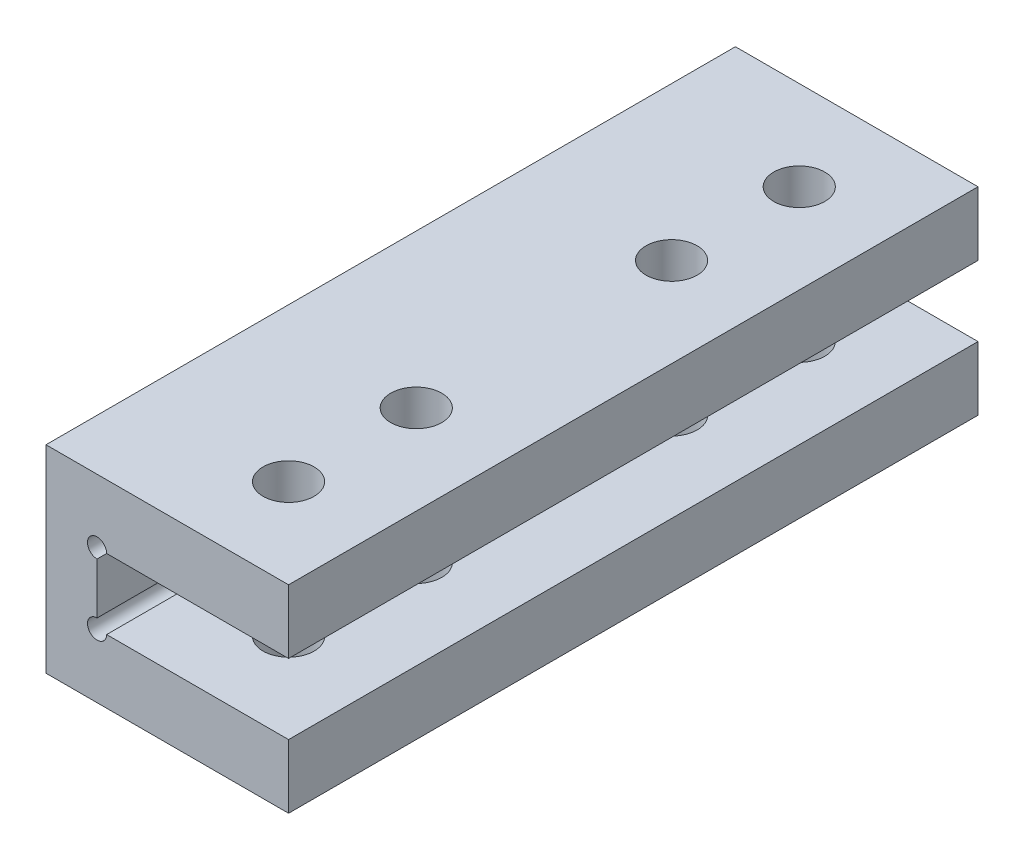
from build123d import *

# Parameters (mm, degrees)
SKETCH1_W           = 15
SKETCH1_H           = 27
SKETCH1_R           = 2
BOSS_EXTRUDE1_DEPTH = 5
SKETCH2_W           = 4
SKETCH2_H           = 10.5
BOSS_EXTRUDE2_DEPTH = 27
SKETCH4_R           = 0.75
CUT_EXTRUDE1_DEPTH  = 54


with BuildPart() as part:
    # Sketch1 → Boss-Extrude1 (new body)
    with BuildSketch(Plane(origin=(0, 0, 0), x_dir=(1, 0, 0), z_dir=(0, 1, 0))):
        with Locations((7.5, 13.5)):
            Rectangle(SKETCH1_W, SKETCH1_H)
        with Locations((8, 10)):
            Circle(SKETCH1_R, mode=Mode.SUBTRACT)
        with Locations((8, 20)):
            Circle(SKETCH1_R, mode=Mode.SUBTRACT)
    extrude(amount=BOSS_EXTRUDE1_DEPTH)

    # Sketch2 → Boss-Extrude2 (add)
    with BuildSketch(Plane.XY):
        with Locations((-2, -0.25)):
            Rectangle(SKETCH2_W, SKETCH2_H)
    extrude(amount=-BOSS_EXTRUDE2_DEPTH)

    # Mirror3: part across plane


with BuildPart() as part_1:
    add(part.part)
    add(part.part.mirror(Plane(origin=(0, -2.75, 0), x_dir=(0, 0, 1), z_dir=(0, -1, 0))))

    # Mirror4: part across plane


with BuildPart() as part_2:
    add(part_1.part)
    add(part_1.part.mirror(Plane(origin=(0, 5, 0), x_dir=(1, 0, 0), z_dir=(0, 0, -1))))

    # Sketch4 → Cut-Extrude1 (cut)
    with BuildSketch(Plane.XY.offset(27)):
        Circle(SKETCH4_R)
        with Locations((0, -5.5)):
            Circle(SKETCH4_R)
    extrude(amount=-CUT_EXTRUDE1_DEPTH, mode=Mode.SUBTRACT)


solid = part_2.part
